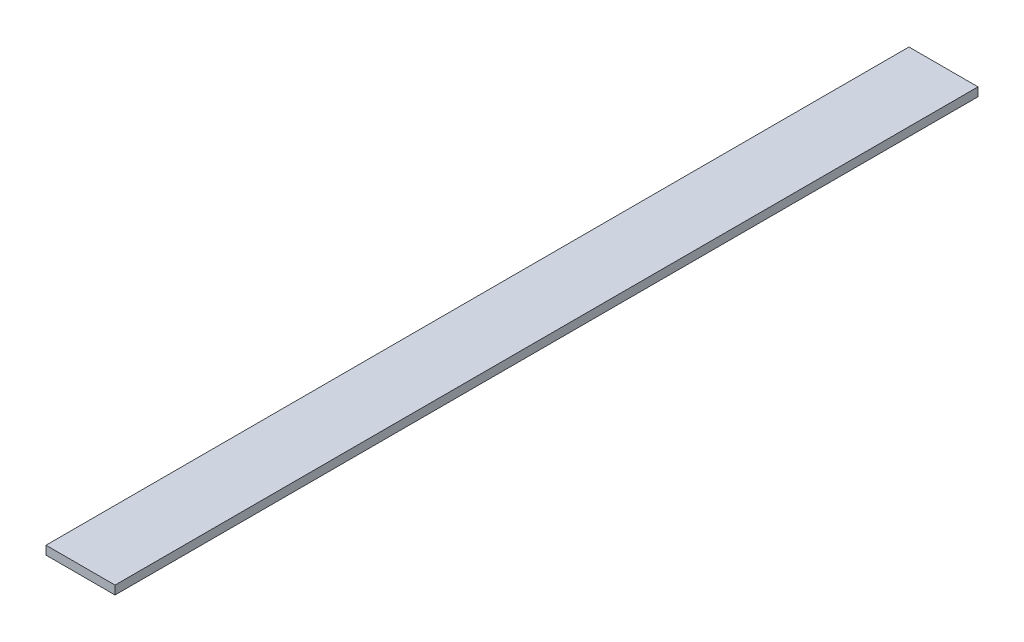
from build123d import *

# Parameters (mm, degrees)
ESQUISSE1_W        = 40
ESQUISSE1_H        = 5
BOSS_EXTRU_1_DEPTH = 500


with BuildPart() as part:
    # Esquisse1 → Boss.-Extru.1 (new body)
    with BuildSketch(Plane.XY):
        with Locations((20, 2.5)):
            Rectangle(ESQUISSE1_W, ESQUISSE1_H)
    extrude(amount=BOSS_EXTRU_1_DEPTH)


solid = part.part
